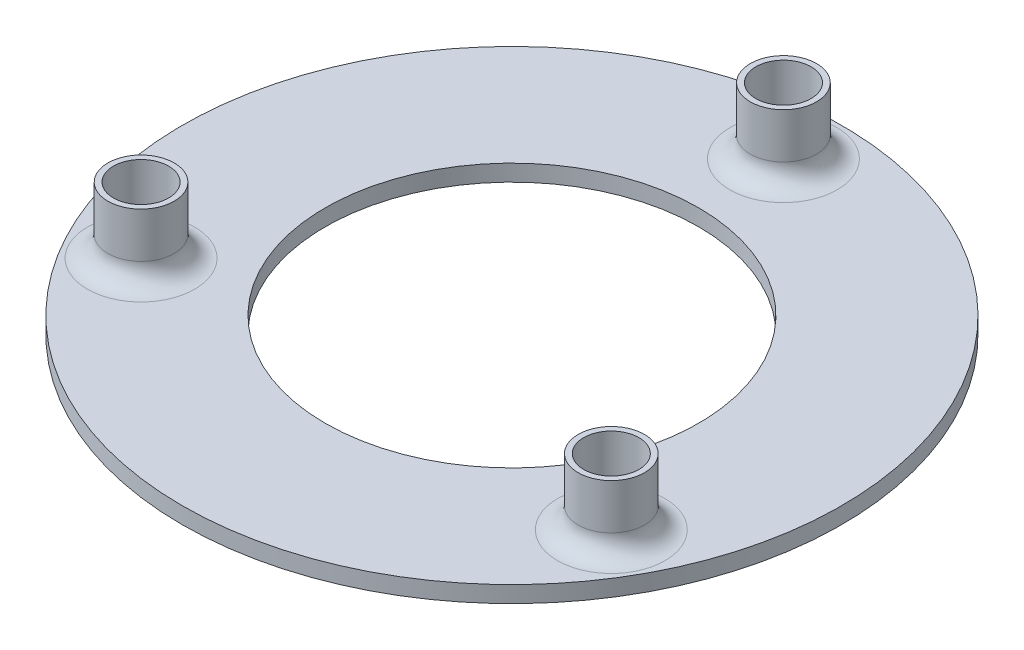
from build123d import *

# Parameters (mm, degrees)
SKETCH4_R           = 80
SKETCH4_R_2         = 45.315839153
BOSS_EXTRUDE1_DEPTH = 4
SKETCH4_3_R         = 8.046061865
SKETCH4_3_R_2       = 6.705051554
BOSS_EXTRUDE2_DEPTH = 20
FILLET1_R           = 5


with BuildPart() as part:
    # Sketch4 → Boss-Extrude1 (new body)
    with BuildSketch(Plane(origin=(0, 0, 0), x_dir=(1, 0, 0), z_dir=(0, 1, 0))):
        Circle(SKETCH4_R)
        Circle(SKETCH4_R_2, mode=Mode.SUBTRACT)
    extrude(amount=BOSS_EXTRUDE1_DEPTH)

    # Sketch4_3 → Boss-Extrude2 (add)
    # profile 1 of 3: a face of its own
    with BuildSketch(Plane(origin=(0, 0, 0), x_dir=(1, 0, 0), z_dir=(0, 1, 0))):
        with Locations((0.001262643, 65.904592273)):
            Circle(SKETCH4_3_R)
        with Locations((0.001262643, 65.904592273)):
            Circle(SKETCH4_3_R_2, mode=Mode.SUBTRACT)
    # profile 2 of 3: a face of its own
    with BuildSketch(Plane(origin=(0, 0, 0), x_dir=(1, 0, 0), z_dir=(0, 1, 0))):
        with Locations((57.077808537, -32.954885136)):
            Circle(SKETCH4_3_R)
        with Locations((57.077808537, -32.954885136)):
            Circle(SKETCH4_3_R_2, mode=Mode.SUBTRACT)
    # profile 3 of 3: a face of its own
    with BuildSketch(Plane(origin=(0, 0, 0), x_dir=(1, 0, 0), z_dir=(0, 1, 0))):
        with Locations((-57.075283251, -32.954885136)):
            Circle(SKETCH4_3_R)
        with Locations((-57.075283251, -32.954885136)):
            Circle(SKETCH4_3_R_2, mode=Mode.SUBTRACT)
    extrude(amount=BOSS_EXTRUDE2_DEPTH)

    # Fillet1
    fillet1_edges = [part.edges().sort_by_distance(p)[0] for p in [
        (49.031746673, 4, 32.954885136),
        (-8.044799222, 4, -65.904592273),
        (-65.121345116, 4, 32.954885136),
    ]]
    fillet(fillet1_edges, radius=FILLET1_R)


solid = part.part
